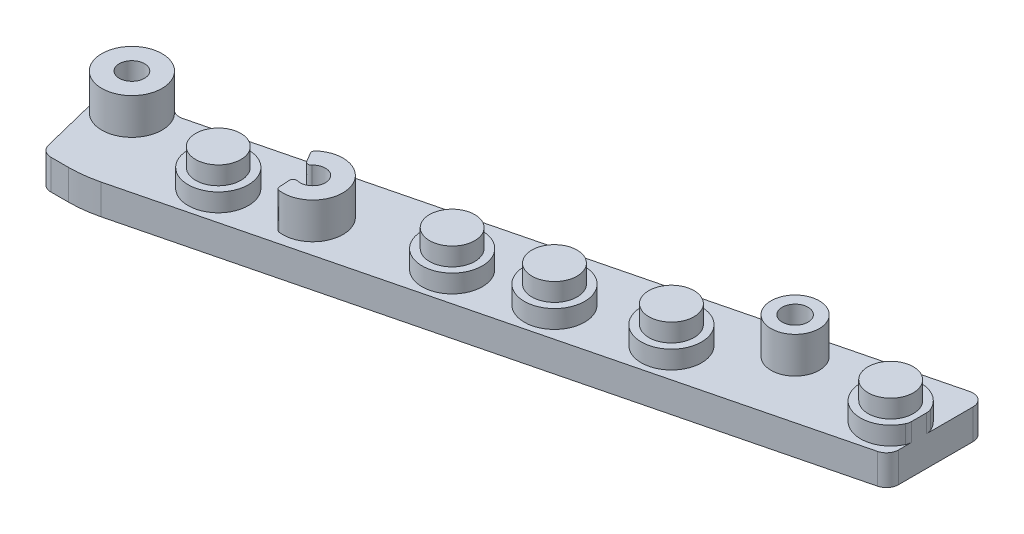
from build123d import *

# Parameters (mm, degrees)
SKETCH1_R               = 2.667
BOSS_EXTRUDE1_DEPTH     = 6.35
SKETCH3_R               = 6.35
BOSS_EXTRUDE2_DEPTH     = 3.81
SKETCH4_R               = 4.7625
BOSS_EXTRUDE3_DEPTH     = 3.81
SKETCH5_R               = 6.35
SKETCH5_R_2             = 2.667
SKETCH5_R_3             = 5.08
SKETCH5_R_4             = 2.723974981
BOSS_EXTRUDE4_DEPTH     = 7.62
SKETCH6_W               = 54.822055163
SKETCH6_H               = 25.4
CUT_EXTRUDE2_DEPTH      = 10.414
CUT_EXTRUDE2_DEPTH_BACK = 156.972


with BuildPart() as part:
    # Sketch1 → Boss-Extrude1 (new body)
    with BuildSketch(Plane(origin=(0, 0, 0), x_dir=(-1, 0, 0), z_dir=(0, 1, 0))):
        with BuildLine():
            Line((132.859114436, 54.06756661), (1.925518385, 21.422154602))
            ThreePointArc((1.925518385, 21.422154602), (0.538452686, 20.521383604), (0, 18.957603457))
            Line((0, 18.957603457), (0, 3.251051746))
            ThreePointArc((0, 3.251051746), (0.976219853, 1.249504432), (3.154481615, 0.786500601))
            Line((3.154481615, 0.786500601), (135.868185597, 33.875743365))
            ThreePointArc((135.868185597, 33.875743365), (137.061865325, 33.884273203), (138.127619437, 33.346581632))
            ThreePointArc((138.127619437, 33.346581632), (145.587943549, 32.789337046), (148.401377862, 39.7212592))
            Line((148.401377862, 39.7212592), (145.116412217, 52.896536778))
            ThreePointArc((145.116412217, 52.896536778), (144.215641219, 54.283602477), (142.651861072, 54.822055163))
            Line((142.651861072, 54.822055163), (139.003930584, 54.822055163))
            ThreePointArc((139.003930584, 54.822055163), (135.908449262, 54.632727415), (132.859114436, 54.06756661))
        make_face()
        with Locations((142.24, 38.185055163)):
            Circle(SKETCH1_R, mode=Mode.SUBTRACT)
        with Locations((27.94, 12.785055202)):
            Circle(SKETCH1_R, mode=Mode.SUBTRACT)
        with Locations((104.14, 38.185055202)):
            Circle(SKETCH1_R, mode=Mode.SUBTRACT)
    boss_extrude1 = extrude(amount=-BOSS_EXTRUDE1_DEPTH)

    # Sketch3 → Boss-Extrude2 (add)
    with BuildSketch(Plane(origin=(0, -6.35, 0), x_dir=(-1, 0, 0), z_dir=(0, -1, 0))):
        with Locations((42.976982051, -23.804158196)):
            Circle(SKETCH3_R)
        with Locations((79.945249222, -33.021382418)):
            Circle(SKETCH3_R)
        with Locations((119.378067538, -42.853088255)):
            Circle(SKETCH3_R)
        with Locations((62.693391209, -28.720011114)):
            Circle(SKETCH3_R)
        with BuildLine():
            Line((0, -13.010825767), (0, -16.16304218))
            ThreePointArc((0, -16.16304218), (0.057532424, -16.700587281), (0.227523413, -17.213780985))
            ThreePointArc((0.227523413, -17.213780985), (12.35871488, -14.586933973), (0.227523413, -11.960086962))
            ThreePointArc((0.227523413, -11.960086962), (0.057532424, -12.473280666), (0, -13.010825767))
        make_face()
    boss_extrude2 = extrude(amount=BOSS_EXTRUDE2_DEPTH)

    # Sketch4 → Boss-Extrude3 (add)
    with BuildSketch(Plane.XZ.offset(10.16)):
        with Locations((-6.00871488, 14.586933973)):
            Circle(SKETCH4_R)
        with Locations((-42.976982051, 23.804158196)):
            Circle(SKETCH4_R)
        with Locations((-62.693391209, 28.720011114)):
            Circle(SKETCH4_R)
        with Locations((-79.945249222, 33.021382418)):
            Circle(SKETCH4_R)
        with Locations((-119.378067538, 42.853088255)):
            Circle(SKETCH4_R)
    boss_extrude3 = extrude(amount=BOSS_EXTRUDE3_DEPTH)

    # Sketch5 → Boss-Extrude4 (add)
    with BuildSketch(Plane.XZ.offset(6.35)):
        with Locations((-142.24, 38.185055163)):
            Circle(SKETCH5_R)
        with Locations((-142.24, 38.185055163)):
            Circle(SKETCH5_R_2, mode=Mode.SUBTRACT)
        with Locations((-27.94, 12.785055202)):
            Circle(SKETCH5_R_3)
        with Locations((-27.94, 12.785055202)):
            Circle(SKETCH5_R_4, mode=Mode.SUBTRACT)
        with BuildLine():
            Line((-105.580163175, 43.777970545), (-105.715311414, 41.562252701))
            ThreePointArc((-105.715311414, 41.562252701), (-105.443232026, 40.931048752), (-104.773674962, 40.775681582))
            ThreePointArc((-104.773674962, 40.775681582), (-101.589970205, 37.403878498), (-106.115998075, 36.393876649))
            ThreePointArc((-106.115998075, 36.393876649), (-106.757692083, 36.64019843), (-107.336634242, 36.269696613))
            Line((-107.336634242, 36.269696613), (-108.465736097, 34.358466745))
            ThreePointArc((-108.465736097, 34.358466745), (-108.561892576, 33.849199875), (-108.310080465, 33.396221428))
            ThreePointArc((-108.310080465, 33.396221428), (-98.068500487, 36.325110669), (-104.912246263, 44.487922463))
            ThreePointArc((-104.912246263, 44.487922463), (-105.374571656, 44.25371306), (-105.580163175, 43.777970545))
        make_face()
    boss_extrude4 = extrude(amount=BOSS_EXTRUDE4_DEPTH)

    # Mirror6: Boss-Extrude1, Boss-Extrude2, Boss-Extrude3, Boss-Extrude4 across plane
    add(boss_extrude1.mirror(Plane(origin=(-139.003930584, 0, 29.422055163), x_dir=(0, 0, 1), z_dir=(0, -1, 0))))
    add(boss_extrude2.mirror(Plane(origin=(-139.003930584, 0, 29.422055163), x_dir=(0, 0, 1), z_dir=(0, -1, 0))))
    add(boss_extrude3.mirror(Plane(origin=(-139.003930584, 0, 29.422055163), x_dir=(0, 0, 1), z_dir=(0, -1, 0))))
    add(boss_extrude4.mirror(Plane(origin=(-139.003930584, 0, 29.422055163), x_dir=(0, 0, 1), z_dir=(0, -1, 0))))

    # Sketch6 → Cut-Extrude2 (cut, two sides)
    with BuildSketch(Plane(origin=(0, 0, 0), x_dir=(0, 0, -1), z_dir=(1, 0, 0))) as cut_extrude2_sk:
        with Locations((-27.411027582, -12.7)):
            Rectangle(SKETCH6_W, SKETCH6_H)
    extrude(amount=CUT_EXTRUDE2_DEPTH, mode=Mode.SUBTRACT)
    extrude(cut_extrude2_sk.sketch, amount=-CUT_EXTRUDE2_DEPTH_BACK, mode=Mode.SUBTRACT)


solid = part.part
